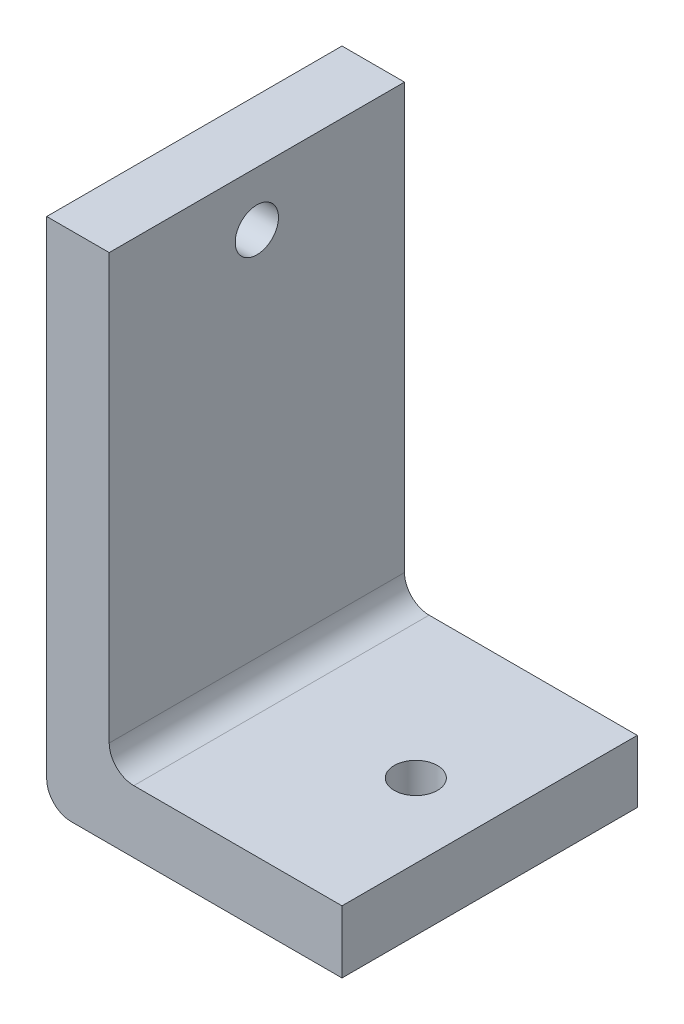
from build123d import *

# Parameters (mm, degrees)
EXTRUDE_THIN1_DEPTH              = 240
SKETCH3_W                        = 35
SKETCH3_H                        = 300
EXTRUDE2_DEPTH                   = 7.35
SKETCH7_W                        = 300
SKETCH7_H                        = 30
EXTRUDE4_DEPTH                   = 7.35
EXTRUDE5_DEPTH                   = 7.35
TAPPED_HOLE_FOR_8_32_HELICOIL1_D = 4.3942
SKETCH26_W                       = 220
SKETCH26_H                       = 70
EXTRUDE18_DEPTH                  = 24.65
EXTRUDE18_DEPTH_BACK             = 7.35
TAPPED_HOLE_FOR_8_32_HELICOIL2_D = 4.3942
FILLET1_R                        = 2.5


with BuildPart() as part:
    # Sketch1 → Extrude-Thin1 (new body)
    with BuildSketch(Plane.XY):
        Polygon((0, 55), (0, 0), (50.8, 0), (50.8, 6.35), (6.35, 6.35), (6.35, 55), align=None)
    extrude(amount=-EXTRUDE_THIN1_DEPTH)

    # Sketch3 → Extrude2 (cut, through all)
    with BuildSketch(Plane(origin=(0, 6.35, 0), x_dir=(1, 0, 0), z_dir=(0, 1, 0))):
        with Locations((47.5, 95)):
            Rectangle(SKETCH3_W, SKETCH3_H)
    extrude(amount=-EXTRUDE2_DEPTH, mode=Mode.SUBTRACT)

    # Sketch7 → Extrude4 (cut, through all)
    with BuildSketch(Plane(origin=(6.35, 0, 0), x_dir=(0, 0, -1), z_dir=(1, 0, 0))):
        with Locations((145, 67)):
            Rectangle(SKETCH7_W, SKETCH7_H)
    extrude(amount=-EXTRUDE4_DEPTH, mode=Mode.SUBTRACT)

    # Sketch10 → Extrude5 (cut, through all)
    with BuildSketch(Plane(origin=(6.35, 0, 0), x_dir=(0, 0, -1), z_dir=(1, 0, 0))):
        with BuildLine():
            Line((30, 67), (210, 67))
            Line((210, 67), (210, 22))
            ThreePointArc((210, 22), (208.535533906, 18.464466094), (205, 17))
            Line((205, 17), (35, 17))
            ThreePointArc((35, 17), (31.464466094, 18.464466094), (30, 22))
            Line((30, 22), (30, 67))
        make_face()
    extrude(amount=-EXTRUDE5_DEPTH, mode=Mode.SUBTRACT)

    # Tapped Hole for #8-32 Helicoil1 (through all)
    with Locations(Plane(origin=(6.35, 46.5, -15), x_dir=(0, 0, 1), z_dir=(1, 0, 0))):
        with Locations((0, 0), (-210, 0)):
            Hole(TAPPED_HOLE_FOR_8_32_HELICOIL1_D / 2)

    # Sketch26 → Extrude18 (cut, two sides)
    with BuildSketch(Plane(origin=(6.35, 0, 0), x_dir=(0, 0, -1), z_dir=(1, 0, 0))) as extrude18_sk:
        with Locations((100, 27)):
            Rectangle(SKETCH26_W, SKETCH26_H)
    extrude(amount=EXTRUDE18_DEPTH, mode=Mode.SUBTRACT)
    extrude(extrude18_sk.sketch, amount=-EXTRUDE18_DEPTH_BACK, mode=Mode.SUBTRACT)

    # Tapped Hole for #8-32 Helicoil2 (through all)
    with Locations(Plane(origin=(22.5, 6.35, -225), x_dir=(0, 0, 1), z_dir=(0, 1, 0))):
        with Locations((0, 0)):
            Hole(TAPPED_HOLE_FOR_8_32_HELICOIL2_D / 2)

    # Fillet1
    fillet1_edges = [part.edges().sort_by_distance(p)[0] for p in [
        (6.35, 6.35, -225),
        (0, 0, -225),
    ]]
    fillet(fillet1_edges, radius=FILLET1_R)


solid = part.part
